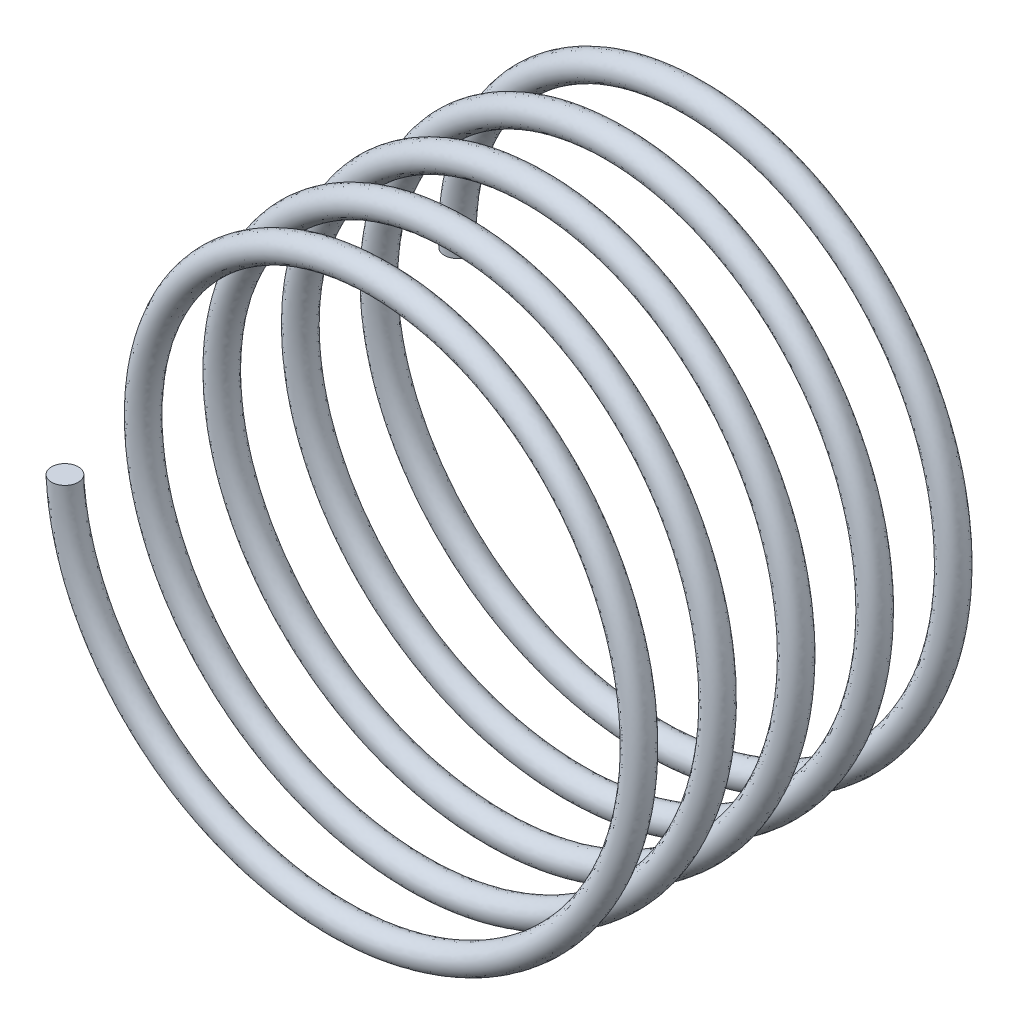
from build123d import *

# Parameters (mm, degrees)
SWEEP1_PITCH       = 1.492
SWEEP1_HEIGHT      = 7.46
SWEEP1_RADIUS      = 5.08
SWEEP1_START_ANGLE = -180
SKETCH4_R          = 0.254


with BuildPart() as part:
    # Sweep1: sweep along a helix
    with BuildLine() as sweep1_path:
        add(Helix(SWEEP1_PITCH, SWEEP1_HEIGHT, SWEEP1_RADIUS, center=(0, 0, 0), direction=(0, 0, 1), lefthand=True, mode=Mode.PRIVATE).rotate(Axis((0, 0, 0), (0, 0, 1)), SWEEP1_START_ANGLE))
    # Sketch4 → Sweep1 (sweep)
    with BuildSketch(Plane(origin=(0, 0, 0), x_dir=(1, 0, 0), z_dir=(0, 1, 0))):
        with Locations((-5.075593906, -7.465039421)):
            Circle(SKETCH4_R)
    sweep(path=sweep1_path.line, is_frenet=True)


solid = part.part
